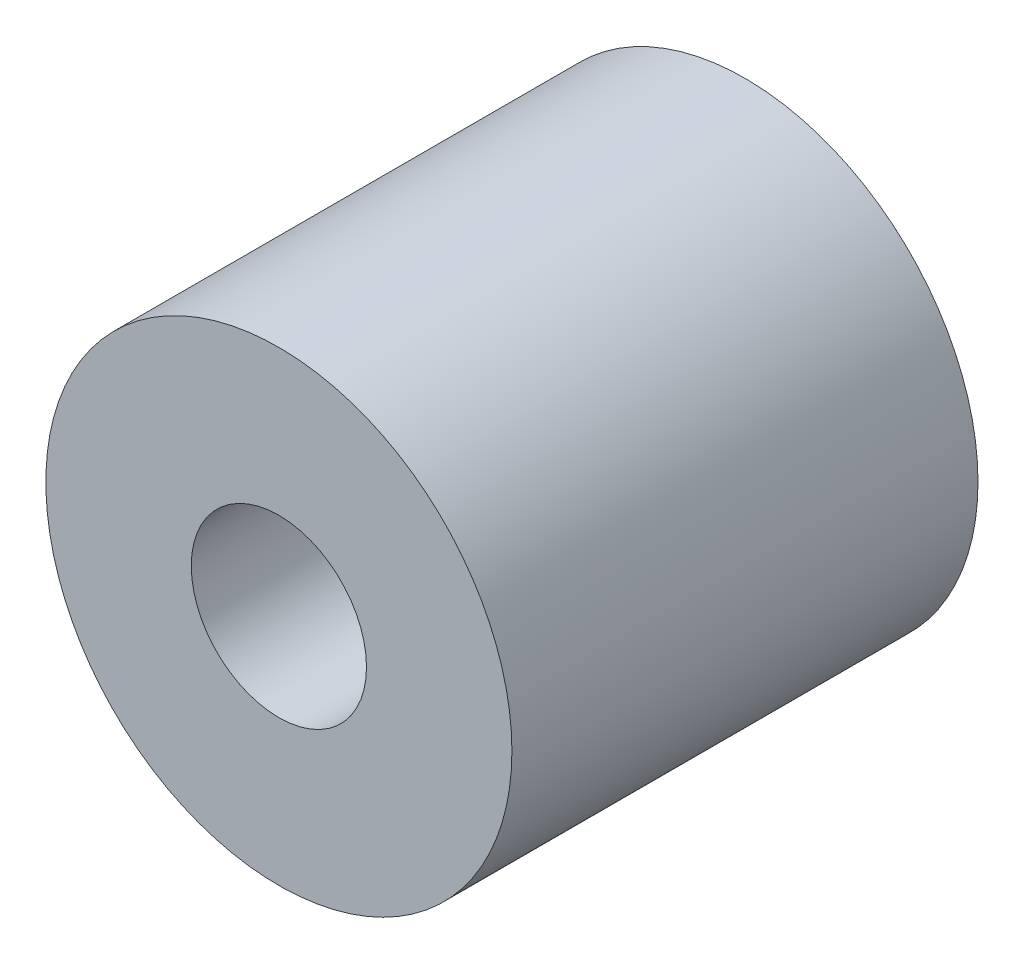
from build123d import *

# Parameters (mm, degrees)
SKETCH1_R      = 3.175
SKETCH1_R_2    = 1.1938
EXTRUDE1_DEPTH = 3.175


with BuildPart() as part:
    # Sketch1 → Extrude1 (new body, symmetric)
    with BuildSketch(Plane.XY):
        Circle(SKETCH1_R)
        Circle(SKETCH1_R_2, mode=Mode.SUBTRACT)
    extrude(amount=EXTRUDE1_DEPTH, both=True)


solid = part.part
